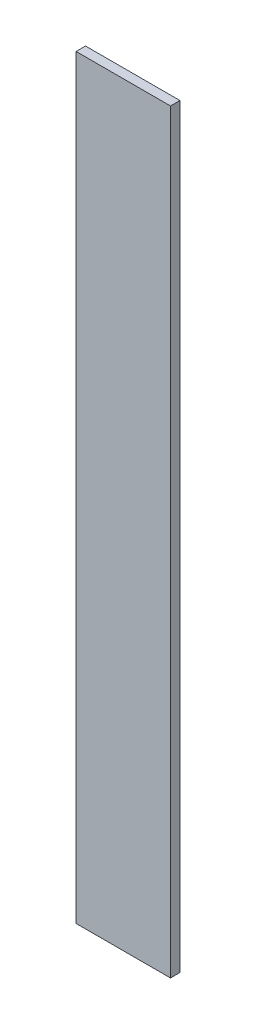
from build123d import *

# Parameters (mm, degrees)
SKETCH1_W           = 25.4
SKETCH1_H           = 203.2
BOSS_EXTRUDE1_DEPTH = 2.54


with BuildPart() as part:
    # Sketch1 → Boss-Extrude1 (new body)
    with BuildSketch(Plane.XY):
        Rectangle(SKETCH1_W, SKETCH1_H)
    extrude(amount=BOSS_EXTRUDE1_DEPTH)


solid = part.part
